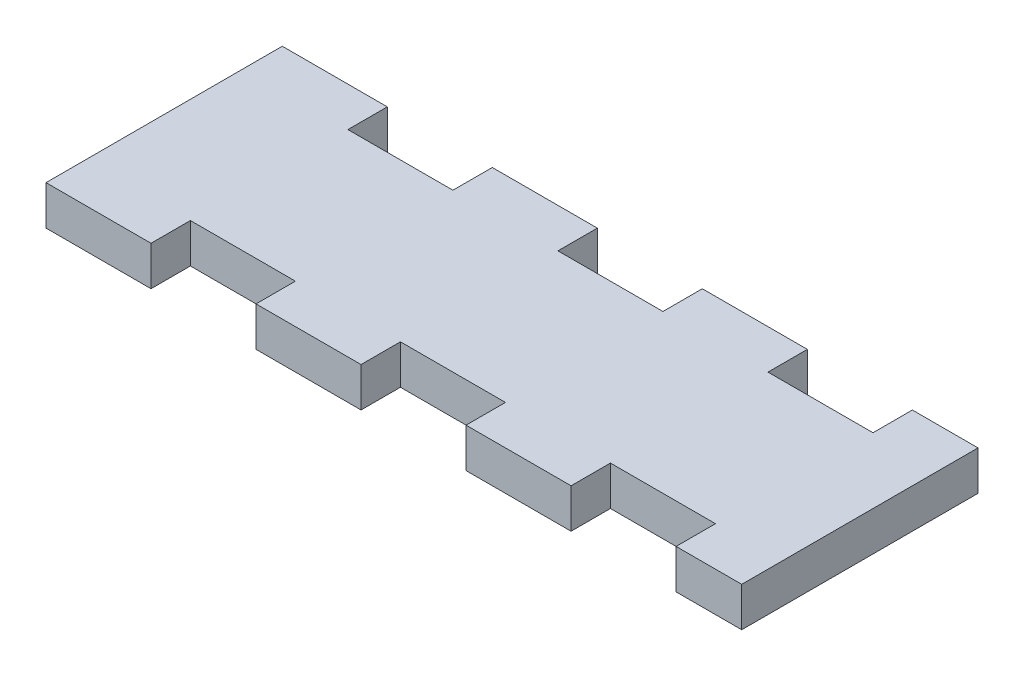
from build123d import *

# Parameters (mm, degrees)
AUFSATZ_LINEAR_AUSTRAGEN1_DEPTH = 3


with BuildPart() as part:
    # Skizze1 → Aufsatz-Linear austragen1 (new body)
    with BuildSketch(Plane(origin=(0, 0, 0), x_dir=(1, 0, 0), z_dir=(0, 1, 0))):
        Polygon((0, 0), (7.99973, 0), (7.99973, 2.999994), (15.999206, 2.999994), (15.999206, 0), (24.000206, 0), (24.000206, 2.999994), (31.999428, 2.999994), (31.999428, 0), (39.999158, 0), (39.999158, 2.999994), (48.000158, 2.999994), (48.000158, 0), (52.99964, 0), (52.99964, 17.99971), (48.000158, 17.99971), (48.000158, 14.999716), (39.999158, 14.999716), (39.999158, 17.99971), (31.999428, 17.99971), (31.999428, 14.999716), (24.000206, 14.999716), (24.000206, 17.99971), (15.999206, 17.99971), (15.999206, 14.999716), (7.99973, 14.999716), (7.99973, 17.99971), (0, 17.99971), align=None)
    extrude(amount=AUFSATZ_LINEAR_AUSTRAGEN1_DEPTH)


solid = part.part
